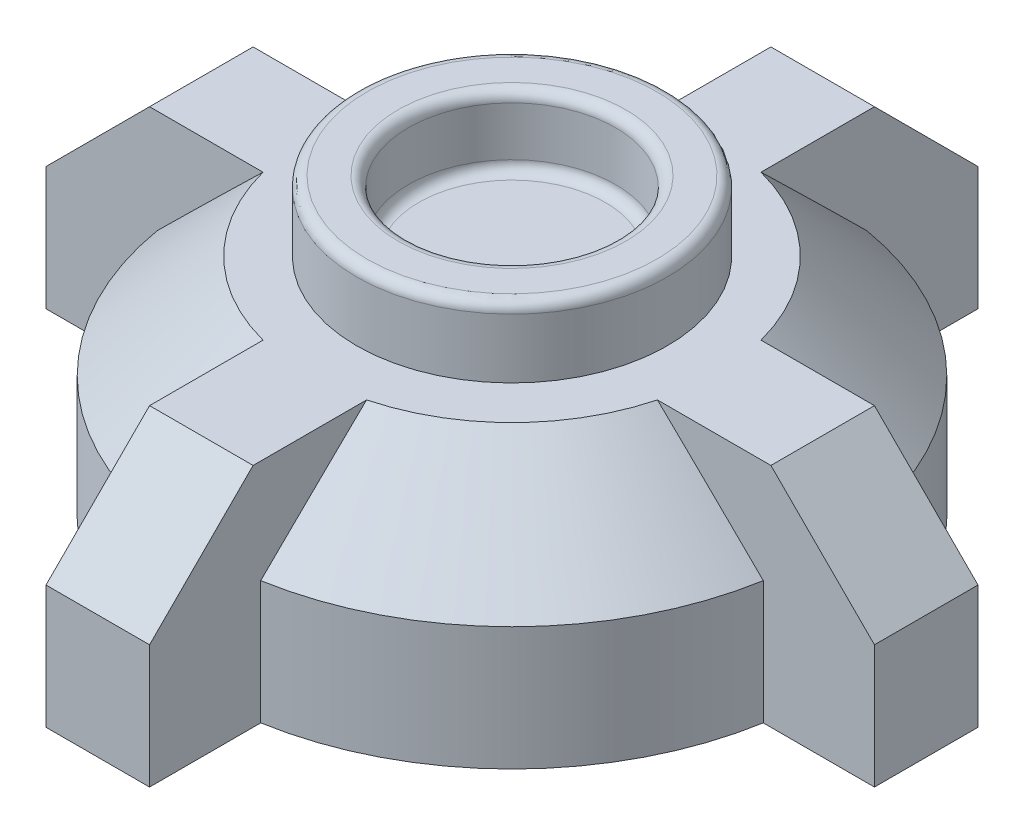
from build123d import *

# Parameters (mm, degrees)
SALIENTE_EXTRUIR1_DEPTH = 43.8
CHAFL_N1_SIZE           = 20
CROQUIS2_R              = 30
CROQUIS2_R_2            = 20
SALIENTE_EXTRUIR2_DEPTH = 13.5
REDONDEO1_R             = 2


with BuildPart() as part:
    # Croquis1 → Saliente-Extruir1 (new body)
    with BuildSketch(Plane(origin=(0, 0, 0), x_dir=(1, 0, 0), z_dir=(0, 1, 0))):
        with BuildLine():
            Line((-10, -58.530413525), (-10, -80))
            Line((-10, -80), (10, -80))
            Line((10, -80), (10, -58.530413525))
            ThreePointArc((10, -58.530413525), (41.986958138, -41.986958138), (58.530413525, -10))
            Line((58.530413525, -10), (80, -10))
            Line((80, -10), (80, 10))
            Line((80, 10), (58.530413525, 10))
            ThreePointArc((58.530413525, 10), (41.986958138, 41.986958138), (10, 58.530413525))
            Line((10, 58.530413525), (10, 80))
            Line((10, 80), (-10, 80))
            Line((-10, 80), (-10, 58.530413525))
            ThreePointArc((-10, 58.530413525), (-41.986958138, 41.986958138), (-58.530413525, 10))
            Line((-58.530413525, 10), (-80, 10))
            Line((-80, 10), (-80, -10))
            Line((-80, -10), (-58.530413525, -10))
            ThreePointArc((-58.530413525, -10), (-41.986958138, -41.986958138), (-10, -58.530413525))
        make_face()
    extrude(amount=SALIENTE_EXTRUIR1_DEPTH)

    # Chaflán1
    chafl_n1_edges = [part.edges().sort_by_distance(p)[0] for p in [
        (-80, 43.8, 0),
        (-41.986958138, 43.8, 41.986958138),
        (0, 43.8, 80),
        (41.986958138, 43.8, 41.986958138),
        (80, 43.8, 0),
        (41.986958138, 43.8, -41.986958138),
        (0, 43.8, -80),
        (-41.986958138, 43.8, -41.986958138),
    ]]
    chamfer(chafl_n1_edges, length=CHAFL_N1_SIZE)

    # Croquis2 → Saliente-Extruir2 (add)
    with BuildSketch(Plane(origin=(0, 43.8, 0), x_dir=(1, 0, 0), z_dir=(0, 1, 0))):
        Circle(CROQUIS2_R)
        Circle(CROQUIS2_R_2, mode=Mode.SUBTRACT)
    extrude(amount=SALIENTE_EXTRUIR2_DEPTH)

    # Redondeo1
    redondeo1_edges = [part.edges().sort_by_distance(p)[0] for p in [
        (-20, 43.8, 0),
        (-30, 57.3, 0),
        (-20, 57.3, 0),
    ]]
    fillet(redondeo1_edges, radius=REDONDEO1_R)


solid = part.part
